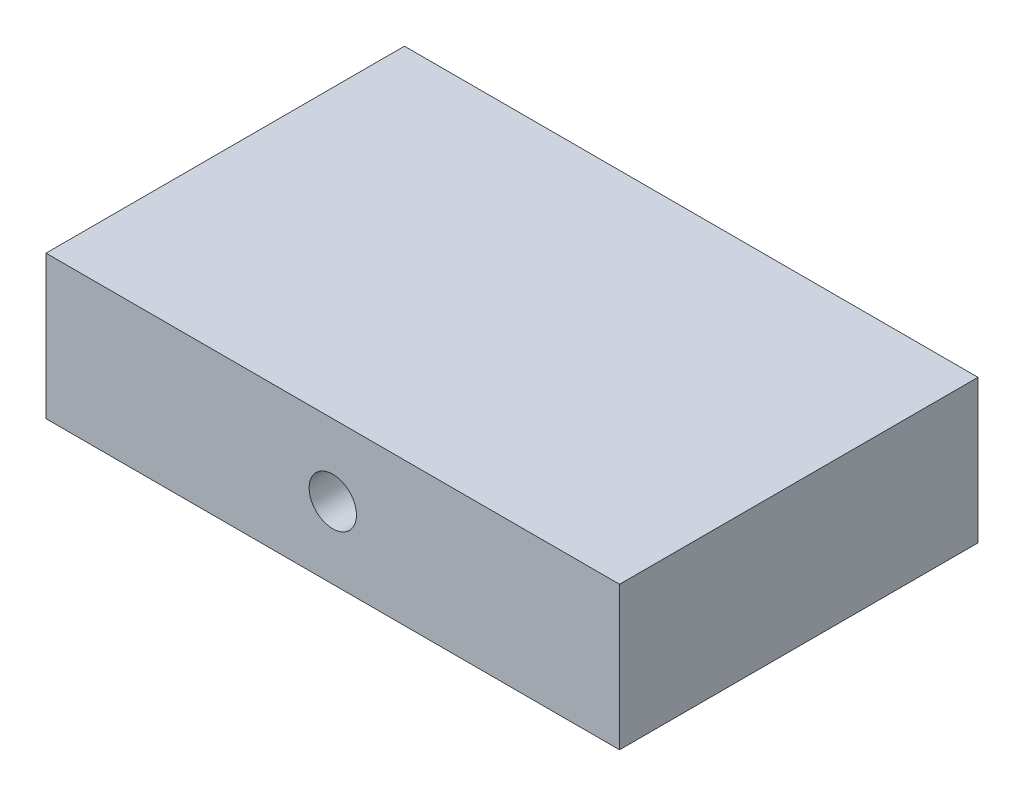
from build123d import *

# Parameters (mm, degrees)
SKETCH1_W             = 40
SKETCH1_H             = 10
BOSS_EXTRUDE1_DEPTH   = 25
M4_TAPPED_HOLE1_D     = 3.3
M4_TAPPED_HOLE1_DEPTH = 9.5
M4_TAPPED_HOLE1_TIP   = 0.991420021


with BuildPart() as part:
    # Sketch1 → Boss-Extrude1 (new body)
    with BuildSketch(Plane.XY):
        with Locations((20, 5)):
            Rectangle(SKETCH1_W, SKETCH1_H)
    extrude(amount=BOSS_EXTRUDE1_DEPTH)

    # M4 Tapped Hole1
    with Locations(Plane(origin=(20, 5, 25), x_dir=(1, 0, 0), z_dir=(0, 0, 1))):
        with Locations((0, 0)):
            Hole(M4_TAPPED_HOLE1_D / 2, depth=M4_TAPPED_HOLE1_DEPTH)
            with Locations((0, 0, -(M4_TAPPED_HOLE1_DEPTH + M4_TAPPED_HOLE1_TIP / 2))):  # 118° drill point
                Cone(0, M4_TAPPED_HOLE1_D / 2, M4_TAPPED_HOLE1_TIP, mode=Mode.SUBTRACT)


solid = part.part
